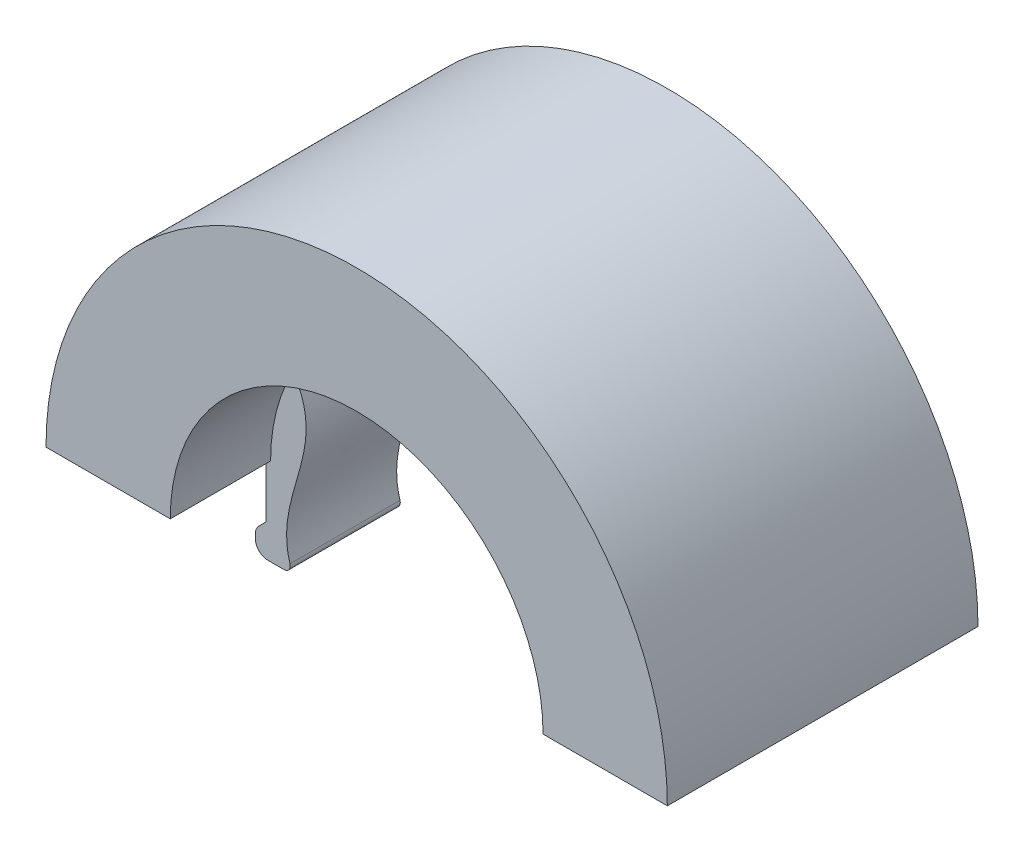
from build123d import *

# Parameters (mm, degrees)
BOSS_EXTRUDE1_DEPTH = 12.5
BOSS_EXTRUDE3_DEPTH = 4.42775
FILLET1_R           = 1
FILLET2_R           = 1
FILLET5_R           = 1
FILLET6_R           = 1
SKETCH4_R           = 3.388
CUT_EXTRUDE1_DEPTH  = 5.656
FILLET7_R           = 0.5


with BuildPart() as part:
    # Sketch1 → Boss-Extrude1 (new body, symmetric)
    with BuildSketch(Plane.XY):
        with BuildLine():
            Line((-25, 0), (-15, 0))
            ThreePointArc((-15, 0), (0, 15), (15, 0))
            Line((15, 0), (25, 0))
            ThreePointArc((25, 0), (0, 25), (-25, 0))
        make_face()
    extrude(amount=BOSS_EXTRUDE1_DEPTH, both=True)

    # Sketch3 → Boss-Extrude3 (add, symmetric)
    with BuildSketch(Plane.XY):
        with BuildLine():
            Line((15.3827, 0), (15.3827, -4.45))
            Line((15.3827, -4.45), (16.2282, -5.2955))
            Line((16.2282, -5.2955), (16.2282, -7.031))
            Line((16.2282, -7.031), (13.2022, -7.031))
            add(Edge.make_bspline(
                [(13.2022, 7.12052773), (9.986819902, 2.44993192), (15.309996934, -2.18235212), (13.2022, -7.031)],
                knots=[0, 0, 0, 0, 1, 1, 1, 1], degree=3))
            ThreePointArc((13.2022, 7.12052773), (14.543606843, 3.671988562), (15, 0))
            Line((15, 0), (15.3827, 0))
        make_face()
    boss_extrude3 = extrude(amount=BOSS_EXTRUDE3_DEPTH, both=True)

    # Mirror11: Boss-Extrude3 across plane
    add(boss_extrude3.mirror(Plane(origin=(0, 0, 0), x_dir=(0, 0, 1), z_dir=(1, 0, 0))))

    # Fillet1
    fillet1_edges = [part.edges().sort_by_distance(p)[0] for p in [
        (16.2282, -7.031, 0),
    ]]
    fillet(fillet1_edges, radius=FILLET1_R)

    # Fillet2
    fillet2_edges = [part.edges().sort_by_distance(p)[0] for p in [
        (-16.2282, -7.031, 0),
    ]]
    fillet(fillet2_edges, radius=FILLET2_R)

    # Fillet5
    fillet5_edges = [part.edges().sort_by_distance(p)[0] for p in [
        (16.2282, -5.2955, 0),
    ]]
    fillet(fillet5_edges, radius=FILLET5_R)

    # Fillet6
    fillet6_edges = [part.edges().sort_by_distance(p)[0] for p in [
        (-16.2282, -5.2955, 0),
    ]]
    fillet(fillet6_edges, radius=FILLET6_R)

    # Sketch4 → Cut-Extrude1 (cut)
    with BuildSketch(Plane.XZ):
        with Locations((20, -4.5)):
            Circle(SKETCH4_R)
        with Locations((20, 4.5)):
            Circle(SKETCH4_R)
    cut_extrude1 = extrude(amount=-CUT_EXTRUDE1_DEPTH, mode=Mode.SUBTRACT)

    # Mirror12: Cut-Extrude1 across plane
    add(cut_extrude1.mirror(Plane(origin=(0, 0, 0), x_dir=(0, 0, 1), z_dir=(1, 0, 0))), mode=Mode.SUBTRACT)

    # Fillet7
    fillet7_edges = [part.edges().sort_by_distance(p)[0] for p in [
        (13.2022, -7.031, 2.213875),
        (-13.2022, -7.031, -2.213875),
    ]]
    fillet(fillet7_edges, radius=FILLET7_R)


solid = part.part
